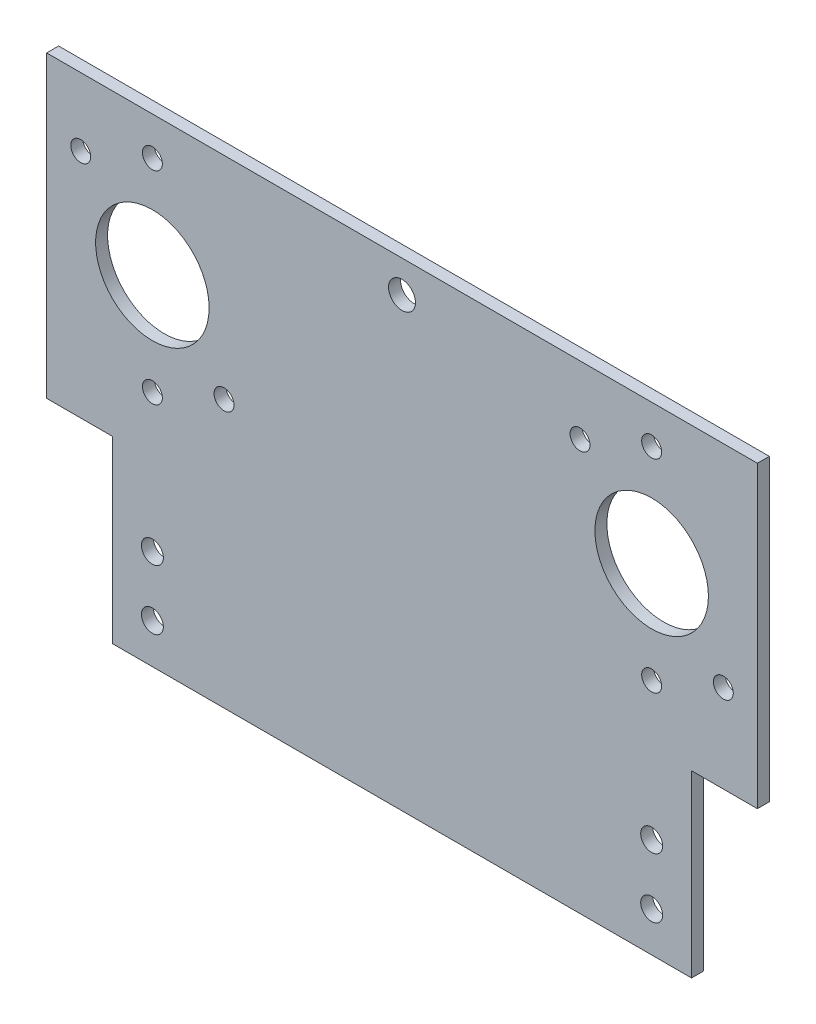
from build123d import *

# Parameters (mm, degrees)
SKETCH1_W           = 178.16
SKETCH1_H           = 120
BOSS_EXTRUDE1_DEPTH = 3
SKETCH2_R           = 14.225
SKETCH2_R_2         = 2.75
SKETCH2_R_3         = 3.375
CUT_EXTRUDE1_DEPTH  = 4
SKETCH3_R           = 2.0193
CUT_EXTRUDE2_DEPTH  = 4
SKETCH6_R           = 2.5
CUT_EXTRUDE3_DEPTH  = 4
SKETCH7_W           = 16.5
SKETCH7_H           = 45
CUT_EXTRUDE4_DEPTH  = 4


with BuildPart() as part:
    # Sketch1 → Boss-Extrude1 (new body)
    with BuildSketch(Plane.XY):
        with Locations((89.08, -60)):
            Rectangle(SKETCH1_W, SKETCH1_H)
    extrude(amount=BOSS_EXTRUDE1_DEPTH)

    # Sketch2 → Cut-Extrude1 (cut, through all)
    with BuildSketch(Plane.XY.offset(3)):
        with Locations((26.5, -35)):
            Circle(SKETCH2_R)
        with Locations((151.66, -35)):
            Circle(SKETCH2_R)
        with Locations((26.5, -110)):
            Circle(SKETCH2_R_2)
        with Locations((151.66, -110)):
            Circle(SKETCH2_R_2)
        with Locations((89.08, -8)):
            Circle(SKETCH2_R_3)
        with Locations((26.5, -95)):
            Circle(SKETCH2_R_2)
        with Locations((151.66, -95)):
            Circle(SKETCH2_R_2)
    extrude(amount=-CUT_EXTRUDE1_DEPTH, mode=Mode.SUBTRACT)

    # Sketch3 → Cut-Extrude2 (cut, through all)
    with BuildSketch(Plane(origin=(0, 0, 0), x_dir=(-1, 0, 0), z_dir=(0, 0, -1))):
        with Locations((-44.460512242, -52.960512242)):
            Circle(SKETCH3_R)
        with Locations((-26.5, -9.6)):
            Circle(SKETCH3_R)
        with Locations((-8.539487758, -17.039487758)):
            Circle(SKETCH3_R)
        with Locations((-26.5, -60.4)):
            Circle(SKETCH3_R)
        with Locations((-133.699487758, -17.039487758)):
            Circle(SKETCH3_R)
        with Locations((-151.66, -9.6)):
            Circle(SKETCH3_R)
        with Locations((-151.66, -60.4)):
            Circle(SKETCH3_R)
        with Locations((-169.620512242, -52.960512242)):
            Circle(SKETCH3_R)
    extrude(amount=-CUT_EXTRUDE2_DEPTH, mode=Mode.SUBTRACT)

    # Sketch6 → Cut-Extrude3 (cut, through all)
    with BuildSketch(Plane.XY.offset(3)):
        with Locations((26.5, -60.4)):
            Circle(SKETCH6_R)
        with Locations((44.460512242, -52.960512242)):
            Circle(SKETCH6_R)
        with Locations((26.5, -9.6)):
            Circle(SKETCH6_R)
        with Locations((8.539487758, -17.039487758)):
            Circle(SKETCH6_R)
        with Locations((169.620512242, -52.960512242)):
            Circle(SKETCH6_R)
        with Locations((151.66, -60.4)):
            Circle(SKETCH6_R)
        with Locations((133.699487758, -17.039487758)):
            Circle(SKETCH6_R)
        with Locations((151.66, -9.6)):
            Circle(SKETCH6_R)
    extrude(amount=-CUT_EXTRUDE3_DEPTH, mode=Mode.SUBTRACT)

    # Sketch7 → Cut-Extrude4 (cut, through all)
    with BuildSketch(Plane.XY.offset(3)):
        with Locations((169.91, -97.5)):
            Rectangle(SKETCH7_W, SKETCH7_H)
        with Locations((8.25, -97.5)):
            Rectangle(SKETCH7_W, SKETCH7_H)
    extrude(amount=-CUT_EXTRUDE4_DEPTH, mode=Mode.SUBTRACT)


solid = part.part
